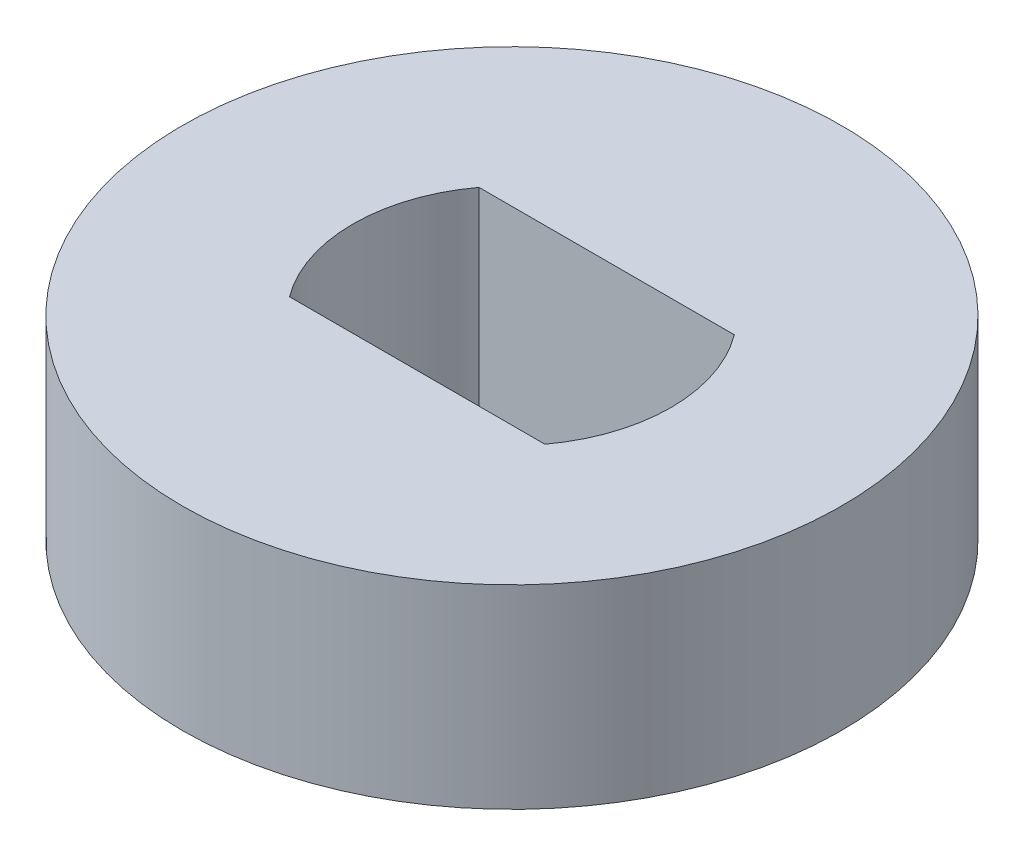
from build123d import *

# Parameters (mm, degrees)
SKETCH1_R           = 5.08
BOSS_EXTRUDE1_DEPTH = 2.9972


with BuildPart() as part:
    # Sketch1 → Boss-Extrude1 (new body)
    with BuildSketch(Plane(origin=(0, 0, 0), x_dir=(1, 0, 0), z_dir=(0, 1, 0))):
        Circle(SKETCH1_R)
        with BuildLine():
            Line((-1.9685, 1.4605), (1.9685, 1.4605))
            ThreePointArc((1.9685, 1.4605), (2.451132901, 0), (1.9685, -1.4605))
            Line((1.9685, -1.4605), (-1.9685, -1.4605))
            ThreePointArc((-1.9685, -1.4605), (-2.451132901, 0), (-1.9685, 1.4605))
        make_face(mode=Mode.SUBTRACT)
    extrude(amount=BOSS_EXTRUDE1_DEPTH)


solid = part.part
